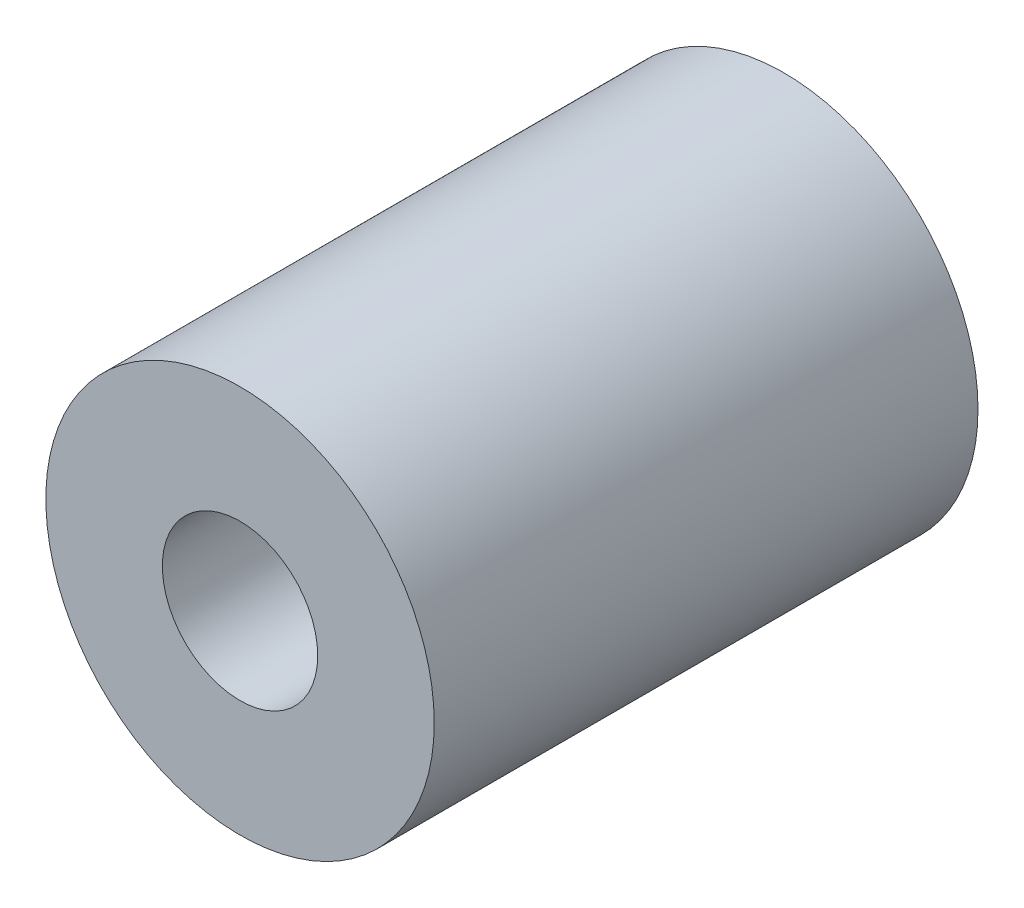
from build123d import *

# Parameters (mm, degrees)
SKETCH1_R                 = 5
BOSS_EXTRUDE1_DEPTH       = 14
F_4_0MM_DOWEL_HOLE1_D     = 4
F_4_0MM_DOWEL_HOLE1_DEPTH = 14


with BuildPart() as part:
    # Sketch1 → Boss-Extrude1 (new body)
    with BuildSketch(Plane.XY):
        Circle(SKETCH1_R)
    extrude(amount=BOSS_EXTRUDE1_DEPTH)

    # Ø4.0mm Dowel Hole1
    with Locations(Plane.XY.offset(14)):
        with Locations((0, 0)):
            Hole(F_4_0MM_DOWEL_HOLE1_D / 2, depth=F_4_0MM_DOWEL_HOLE1_DEPTH)


solid = part.part
